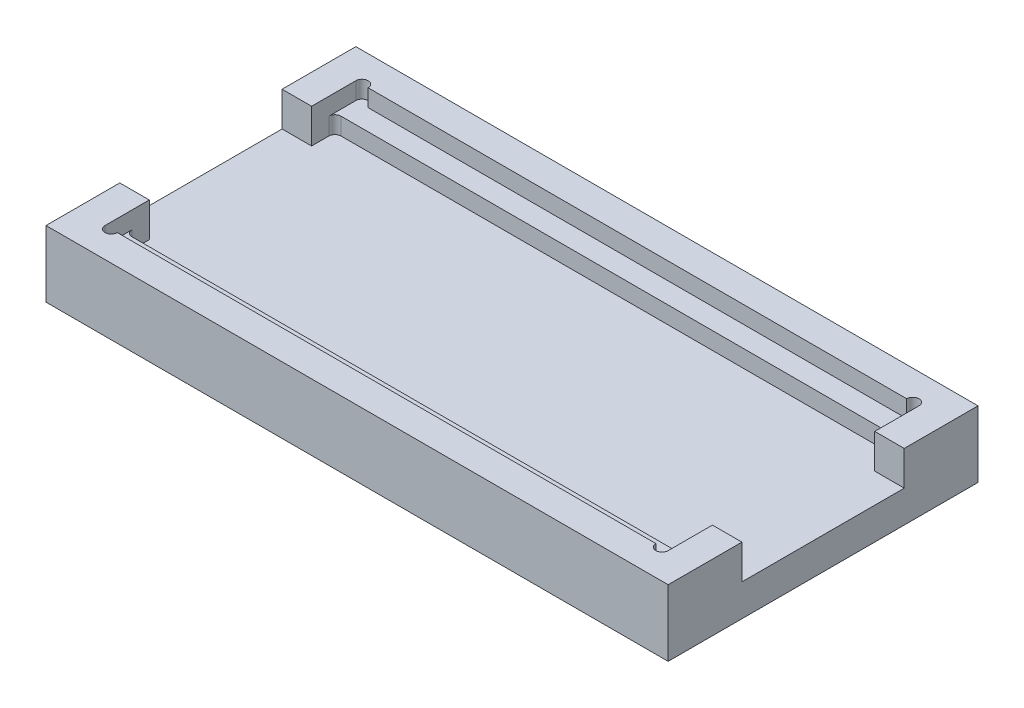
from build123d import *

# Parameters (mm, degrees)
SKETCH1_W           = 253
SKETCH1_H           = 126
BOSS_EXTRUDE1_DEPTH = 27
SKETCH2_W           = 229
SKETCH2_H           = 102
CUT_EXTRUDE1_DEPTH  = 7
SKETCH3_W           = 229
SKETCH3_H           = 85
CUT_EXTRUDE2_DEPTH  = 7
SKETCH4_W           = 12
SKETCH4_H           = 66
CUT_EXTRUDE3_DEPTH  = 14
SKETCH5_W           = 12
SKETCH5_H           = 66
CUT_EXTRUDE4_DEPTH  = 14
CUT_EXTRUDE5_DEPTH  = 7
FILLET1_R           = 2.5


with BuildPart() as part:
    # Sketch1 → Boss-Extrude1 (new body)
    with BuildSketch(Plane(origin=(0, 0, 0), x_dir=(1, 0, 0), z_dir=(0, 1, 0))):
        with Locations((126.5, 63)):
            Rectangle(SKETCH1_W, SKETCH1_H)
    extrude(amount=BOSS_EXTRUDE1_DEPTH)

    # Sketch2 → Cut-Extrude1 (cut)
    with BuildSketch(Plane(origin=(0, 27, 0), x_dir=(1, 0, 0), z_dir=(0, 1, 0))):
        with Locations((126.5, 63)):
            Rectangle(SKETCH2_W, SKETCH2_H)
    extrude(amount=-CUT_EXTRUDE1_DEPTH, mode=Mode.SUBTRACT)

    # Sketch3 → Cut-Extrude2 (cut)
    with BuildSketch(Plane(origin=(0, 20, 0), x_dir=(1, 0, 0), z_dir=(0, 1, 0))):
        with Locations((126.5, 63)):
            Rectangle(SKETCH3_W, SKETCH3_H)
    extrude(amount=-CUT_EXTRUDE2_DEPTH, mode=Mode.SUBTRACT)

    # Sketch4 → Cut-Extrude3 (cut)
    with BuildSketch(Plane(origin=(0, 27, 0), x_dir=(1, 0, 0), z_dir=(0, 1, 0))):
        with Locations((6, 63)):
            Rectangle(SKETCH4_W, SKETCH4_H)
    extrude(amount=-CUT_EXTRUDE3_DEPTH, mode=Mode.SUBTRACT)

    # Sketch5 → Cut-Extrude4 (cut)
    with BuildSketch(Plane(origin=(0, 27, 0), x_dir=(1, 0, 0), z_dir=(0, 1, 0))):
        with Locations((247, 63)):
            Rectangle(SKETCH5_W, SKETCH5_H)
    extrude(amount=-CUT_EXTRUDE4_DEPTH, mode=Mode.SUBTRACT)

    # Sketch6 → Cut-Extrude5 (cut)
    with BuildSketch(Plane(origin=(0, 27, 0), x_dir=(1, 0, 0), z_dir=(0, 1, 0))):
        with BuildLine():
            Line((12, 12), (17, 12))
            ThreePointArc((17, 12), (14.5, 9.5), (12, 12))
        make_face()
        with BuildLine():
            Line((236, 12), (241, 12))
            ThreePointArc((241, 12), (238.5, 9.5), (236, 12))
        make_face()
        with BuildLine():
            Line((12, 114), (17, 114))
            ThreePointArc((17, 114), (14.5, 116.5), (12, 114))
        make_face()
        with BuildLine():
            Line((236, 114), (241, 114))
            ThreePointArc((241, 114), (238.5, 116.5), (236, 114))
        make_face()
    extrude(amount=-CUT_EXTRUDE5_DEPTH, mode=Mode.SUBTRACT)

    # Fillet1
    fillet1_edges = [part.edges().sort_by_distance(p)[0] for p in [
        (241, 16.5, -105.5),
        (241, 16.5, -20.5),
        (12, 16.5, -20.5),
        (12, 16.5, -105.5),
    ]]
    fillet(fillet1_edges, radius=FILLET1_R)


solid = part.part
